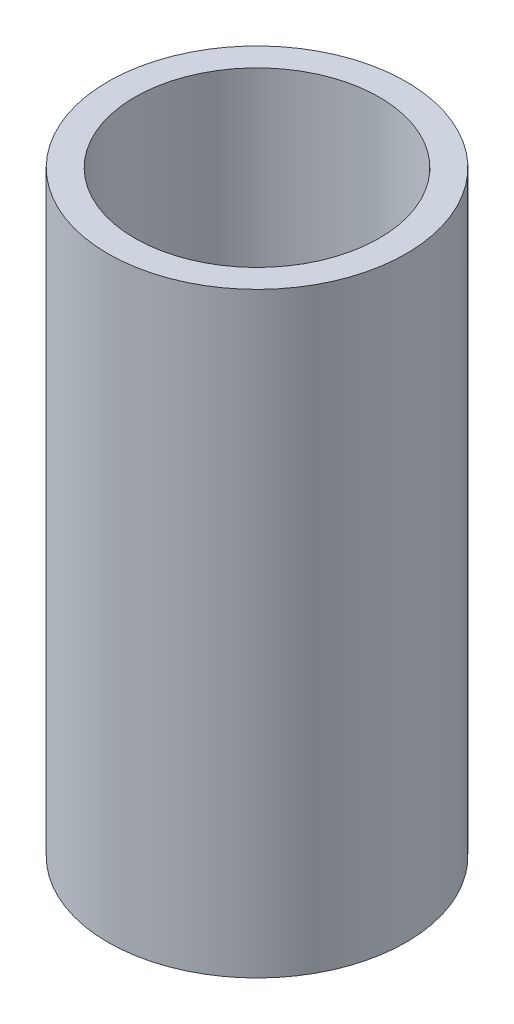
from build123d import *

# Parameters (mm, degrees)
SKETCH1_R           = 12.7
SKETCH1_R_2         = 10.414
BOSS_EXTRUDE1_DEPTH = 50.8


with BuildPart() as part:
    # Sketch1 → Boss-Extrude1 (new body)
    with BuildSketch(Plane(origin=(0, 0, 0), x_dir=(1, 0, 0), z_dir=(0, 1, 0))):
        Circle(SKETCH1_R)
        Circle(SKETCH1_R_2, mode=Mode.SUBTRACT)
    extrude(amount=BOSS_EXTRUDE1_DEPTH)


solid = part.part
